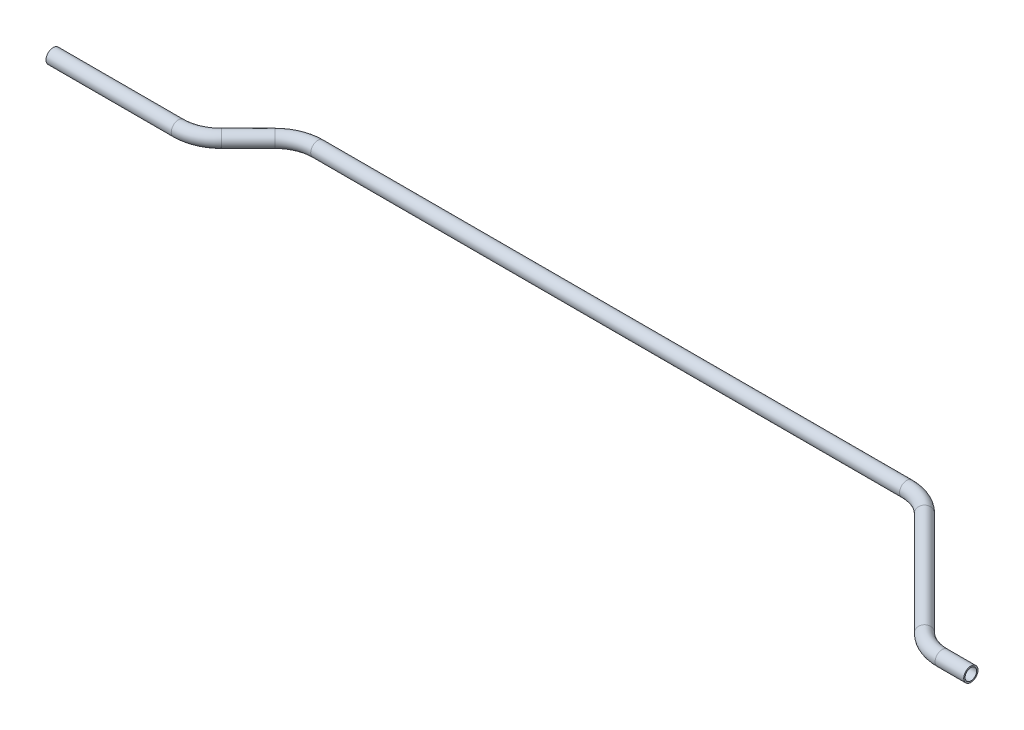
from build123d import *

# Parameters (mm, degrees)
SKETCH2_R   = 6.35
SKETCH2_R_2 = 5.1054


with BuildPart() as part:
    # Sweep1: sweep along a path in Sketch1
    with BuildLine(Plane(origin=(0, 0, 0), x_dir=(1, 0, 0), z_dir=(0, 1, 0))) as sweep1_path:
        Line((0, 0), (111.218463274, 0))
        ThreePointArc((111.218463274, 0), (125.798702047, 2.900189811), (138.159231637, 11.159231637))
        Line((138.159231637, 11.159231637), (161.984627155, 34.984627155))
        ThreePointArc((161.984627155, 34.984627155), (174.345156745, 43.24366898), (188.925395518, 46.143858792))
        Line((188.925395518, 46.143858792), (711.813325339, 46.143858792))
        ThreePointArc((711.813325339, 46.143858792), (726.393564112, 43.24366898), (738.754093702, 34.984627155))
        Line((738.754093702, 34.984627155), (830.735630428, -56.996909572))
        ThreePointArc((830.735630428, -56.996909572), (843.096160018, -65.255951397), (857.676398792, -68.156141208))
        Line((857.676398792, -68.156141208), (883.076398792, -68.156141208))
    # Sketch2 → Sweep1 (sweep)
    with BuildSketch(Plane(origin=(0, 0, 0), x_dir=(0, 0, -1), z_dir=(1, 0, 0))):
        Circle(SKETCH2_R)
        Circle(SKETCH2_R_2, mode=Mode.SUBTRACT)
    sweep(path=sweep1_path.line)


solid = part.part
